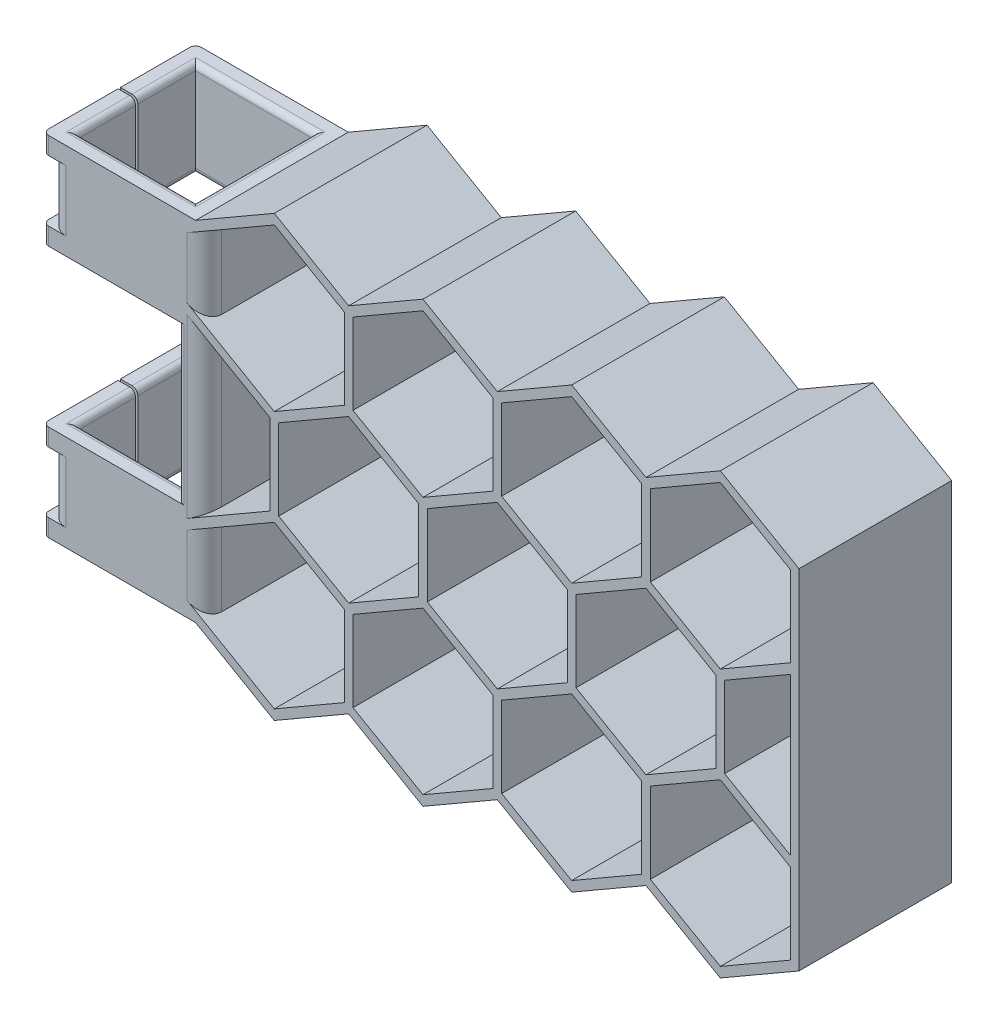
from build123d import *

# Parameters (mm, degrees)
SKETCH1_W                  = 26.3
SKETCH1_H                  = 26.3
SKETCH1_W_2                = 20.3
SKETCH1_H_2                = 20.3
TUBE_EXTRUDE_DEPTH         = 60
HEX_EXTRUDE_DEPTH          = 26.3
SKETCH3_W                  = 23.3
SKETCH3_H                  = 26.968911086
TUBE_CENTER_CUT_DEPTH      = 1
TUBE_CENTER_CUT_DEPTH_BACK = 27.3
CUT_EXTRUDE1_START         = -3
CUT_EXTRUDE1_DEPTH         = 3
SKETCH5_W                  = 1
SKETCH5_H                  = 10.515544457
CUT_EXTRUDE2_DEPTH         = 27.3
FILLET1_R                  = 3
FILLET2_R                  = 1


with BuildPart() as part:
    # Sketch1 → Tube Extrude (new body)
    with BuildSketch(Plane(origin=(0, 0, 0), x_dir=(1, 0, 0), z_dir=(0, 1, 0))):
        with Locations((10.15, 10.15)):
            Rectangle(SKETCH1_W, SKETCH1_H)
        with Locations((10.15, 10.15)):
            Rectangle(SKETCH1_W_2, SKETCH1_H_2, mode=Mode.SUBTRACT)
    extrude(amount=TUBE_EXTRUDE_DEPTH)

    # Sketch2 → Hex Extrude (add)
    with BuildSketch(Plane.XY.offset(3)):
        Polygon((23.3, 15.649519053), (23.3, 0), (36.852881057, -7.824759526), (49.655762114, -0.433012702), (62.45864317, -7.824759526), (75.261524227, -0.433012702), (88.064405284, -7.824759526), (100.867286341, -0.433012702), (113.670167397, -7.824759526), (127.223048454, 0), (127.223048454, 15.649519053), (127.223048454, 44.350480947), (127.223048454, 60), (113.670167397, 67.824759526), (100.867286341, 60.433012702), (88.064405284, 67.824759526), (75.261524227, 60.433012702), (62.45864317, 67.824759526), (49.655762114, 60.433012702), (36.852881057, 67.824759526), (23.3, 60), (23.3, 44.350480947), align=None)
        Polygon((49.655762114, 16.082531755), (37.602881057, 23.041265877), (37.602881057, 36.958734123), (49.655762114, 43.917468245), (61.70864317, 36.958734123), (61.70864317, 23.041265877), align=None, mode=Mode.SUBTRACT)
        Polygon((36.102881057, 23.041265877), (24.8, 16.515544457), (24.8, 43.484455543), (36.102881057, 36.958734123), align=None, mode=Mode.SUBTRACT)
        Polygon((24.8, 0.866025404), (36.852881057, -6.092708719), (48.905762114, 0.866025404), (48.905762114, 14.783493649), (36.852881057, 21.742227772), (24.8, 14.783493649), align=None, mode=Mode.SUBTRACT)
        Polygon((50.405762114, 0.866025404), (62.45864317, -6.092708719), (74.511524227, 0.866025404), (74.511524227, 14.783493649), (62.45864317, 21.742227772), (50.405762114, 14.783493649), align=None, mode=Mode.SUBTRACT)
        Polygon((76.011524227, 0.866025404), (88.064405284, -6.092708719), (100.117286341, 0.866025404), (100.117286341, 14.783493649), (88.064405284, 21.742227772), (76.011524227, 14.783493649), align=None, mode=Mode.SUBTRACT)
        Polygon((125.723048454, 16.515544457), (114.420167397, 23.041265877), (114.420167397, 36.958734123), (125.723048454, 43.484455543), align=None, mode=Mode.SUBTRACT)
        Polygon((101.617286341, 0.866025404), (113.670167397, -6.092708719), (125.723048454, 0.866025404), (125.723048454, 14.783493649), (113.670167397, 21.742227772), (101.617286341, 14.783493649), align=None, mode=Mode.SUBTRACT)
        Polygon((24.8, 45.216506351), (36.852881057, 38.257772228), (48.905762114, 45.216506351), (48.905762114, 59.133974596), (36.852881057, 66.092708719), (24.8, 59.133974596), align=None, mode=Mode.SUBTRACT)
        Polygon((50.405762114, 45.216506351), (62.45864317, 38.257772228), (74.511524227, 45.216506351), (74.511524227, 59.133974596), (62.45864317, 66.092708719), (50.405762114, 59.133974596), align=None, mode=Mode.SUBTRACT)
        Polygon((76.011524227, 45.216506351), (88.064405284, 38.257772228), (100.117286341, 45.216506351), (100.117286341, 59.133974596), (88.064405284, 66.092708719), (76.011524227, 59.133974596), align=None, mode=Mode.SUBTRACT)
        Polygon((101.617286341, 45.216506351), (113.670167397, 38.257772228), (125.723048454, 45.216506351), (125.723048454, 59.133974596), (113.670167397, 66.092708719), (101.617286341, 59.133974596), align=None, mode=Mode.SUBTRACT)
        Polygon((75.261524227, 16.082531755), (87.314405284, 23.041265877), (87.314405284, 36.958734123), (75.261524227, 43.917468245), (63.20864317, 36.958734123), (63.20864317, 23.041265877), align=None, mode=Mode.SUBTRACT)
        Polygon((100.867286341, 16.082531755), (112.920167397, 23.041265877), (112.920167397, 36.958734123), (100.867286341, 43.917468245), (88.814405284, 36.958734123), (88.814405284, 23.041265877), align=None, mode=Mode.SUBTRACT)
    extrude(amount=-HEX_EXTRUDE_DEPTH)

    # Sketch3 → Tube Center Cut (cut, two sides)
    with BuildSketch(Plane.XY.offset(3)) as tube_center_cut_sk:
        with Locations((8.65, 30)):
            Rectangle(SKETCH3_W, SKETCH3_H)
    extrude(amount=TUBE_CENTER_CUT_DEPTH, mode=Mode.SUBTRACT)
    extrude(tube_center_cut_sk.sketch, amount=-TUBE_CENTER_CUT_DEPTH_BACK, mode=Mode.SUBTRACT)

    # Sketch4 → Cut-Extrude1 (cut)
    with BuildSketch(Plane.ZY.offset(3).offset(CUT_EXTRUDE1_START)):
        Polygon((-10.15, 60), (-10.35, 60), (-10.35, 0), (-10.15, 0), (-9.95, 0), (-9.95, 60), align=None)
    extrude(amount=CUT_EXTRUDE1_DEPTH, mode=Mode.SUBTRACT)

    # Sketch5 → Cut-Extrude2 (cut, through all)
    with BuildSketch(Plane.XY.offset(3)):
        with Locations((-2.5, 51.742227771)):
            Rectangle(SKETCH5_W, SKETCH5_H)
        with Locations((-2.5, 8.257772229)):
            Rectangle(SKETCH5_W, SKETCH5_H)
    extrude(amount=-CUT_EXTRUDE2_DEPTH, mode=Mode.SUBTRACT)

    # Fillet1
    fillet1_edges = [part.edges().sort_by_distance(p)[0] for p in [
        (-2, 51.742227772, -23.3),
        (-2, 51.742227772, 3),
        (-2, 8.257772228, -23.3),
        (-2, 8.257772228, 3),
        (24.8, 52.175240474, -23.3),
        (24.8, 52.175240474, 3),
        (24.8, 7.824759526, -23.3),
        (24.8, 7.824759526, 3),
        (24.8, 30, 3),
        (24.8, 30, -23.3),
    ]]
    fillet(fillet1_edges, radius=FILLET1_R)

    # Fillet2
    fillet2_edges = [part.edges().sort_by_distance(p)[0] for p in [
        (0, 0, -15.325),
        (10.15, 0, 0),
        (20.3, 0, -10.15),
        (10.15, 0, -20.3),
        (0, 60, -15.325),
        (10.15, 60, 0),
        (20.3, 60, -10.15),
        (10.15, 60, -20.3),
        (10.15, 43.484455543, -20.3),
        (10.15, 16.515544457, -20.3),
        (-3, 15.015544457, -23.3),
        (-3, 15.015544457, 3),
        (20.3, 30, 3),
        (10.15, 16.515544457, 0),
        (0, 16.515544457, -4.975),
        (0, 43.484455543, -15.325),
        (10.15, 43.484455543, 0),
        (20.3, 30, -23.3),
        (0, 43.484455543, -4.975),
        (0, 16.515544457, -15.325),
        (0, 60, -4.975),
        (0, 0, -4.975),
        (-3, 1.5, -23.3),
        (-3, 44.984455543, -23.3),
        (-3, 1.5, 3),
        (-3, 44.984455543, 3),
        (-3, 58.5, -23.3),
        (-3, 58.5, 3),
    ]]
    fillet(fillet2_edges, radius=FILLET2_R)


solid = part.part
